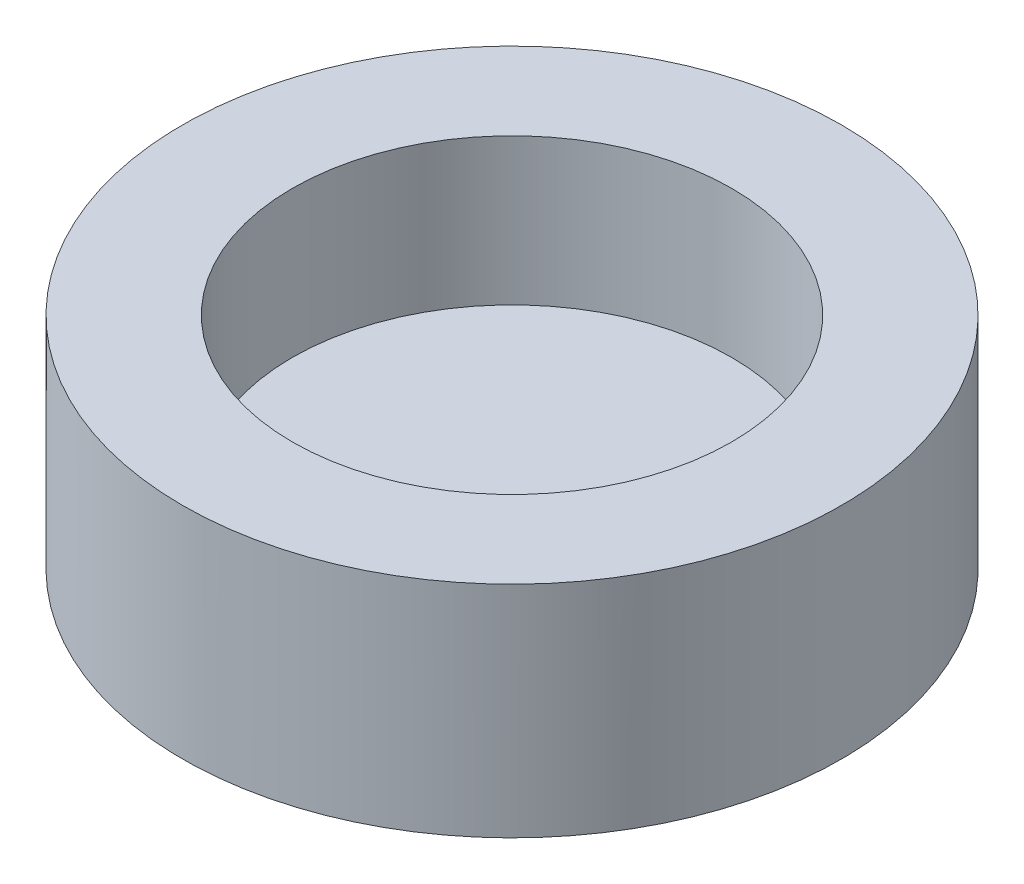
from build123d import *

# Parameters (mm, degrees)
SKETCH1_R           = 22.5
SKETCH1_R_2         = 15
BOSS_EXTRUDE1_DEPTH = 10
SKETCH2_R           = 22.5
BOSS_EXTRUDE2_DEPTH = 5


with BuildPart() as part:
    # Sketch1 → Boss-Extrude1 (new body)
    with BuildSketch(Plane(origin=(0, 0, 0), x_dir=(1, 0, 0), z_dir=(0, 1, 0))):
        Circle(SKETCH1_R)
        Circle(SKETCH1_R_2, mode=Mode.SUBTRACT)
    extrude(amount=BOSS_EXTRUDE1_DEPTH)

    # Sketch2 → Boss-Extrude2 (add)
    with BuildSketch(Plane.XZ):
        Circle(SKETCH2_R)
    extrude(amount=BOSS_EXTRUDE2_DEPTH)


solid = part.part
